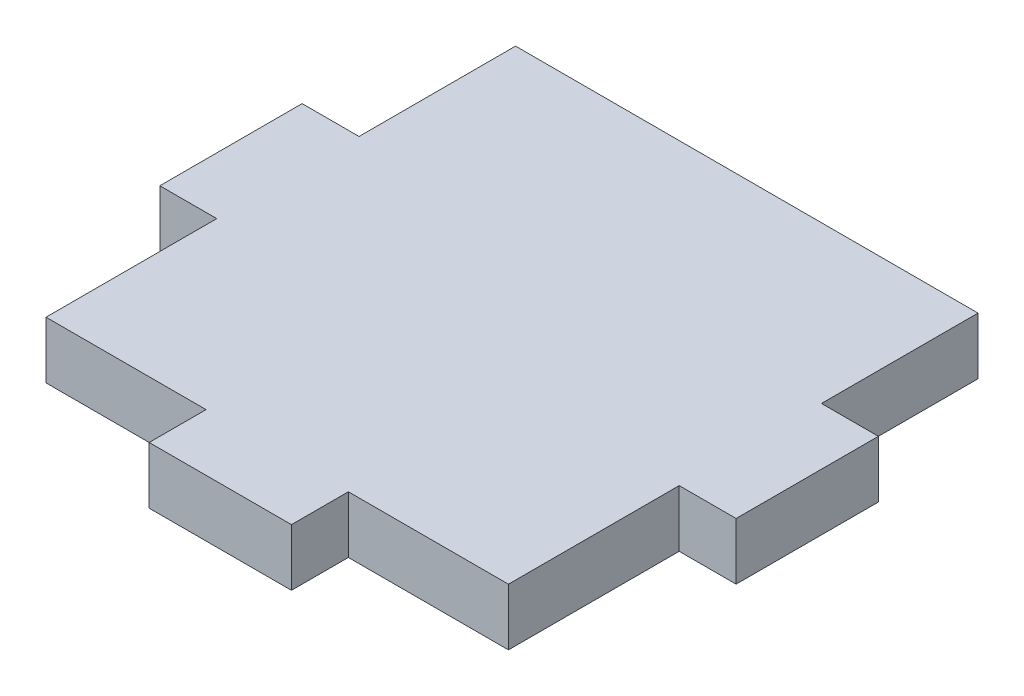
from build123d import *

# Parameters (mm, degrees)
SKETCH1_W           = 32.5
SKETCH1_H           = 33
BOSS_EXTRUDE1_DEPTH = 4
SKETCH2_W           = 10
SKETCH2_H           = 4
SKETCH2_W_2         = 4
SKETCH2_H_2         = 10
BOSS_EXTRUDE2_DEPTH = 4


with BuildPart() as part:
    # Sketch1 → Boss-Extrude1 (new body)
    with BuildSketch(Plane(origin=(0, 0, 0), x_dir=(1, 0, 0), z_dir=(0, 1, 0))):
        with Locations((16.25, -16.5)):
            Rectangle(SKETCH1_W, SKETCH1_H)
    extrude(amount=BOSS_EXTRUDE1_DEPTH)

    # Sketch2 → Boss-Extrude2 (add, through all)
    with BuildSketch(Plane.XZ):
        with Locations((16.25, 35)):
            Rectangle(SKETCH2_W, SKETCH2_H)
        with Locations((34.5, 16)):
            Rectangle(SKETCH2_W_2, SKETCH2_H_2)
        with Locations((-2, 16)):
            Rectangle(SKETCH2_W_2, SKETCH2_H_2)
    extrude(amount=-BOSS_EXTRUDE2_DEPTH)


solid = part.part
